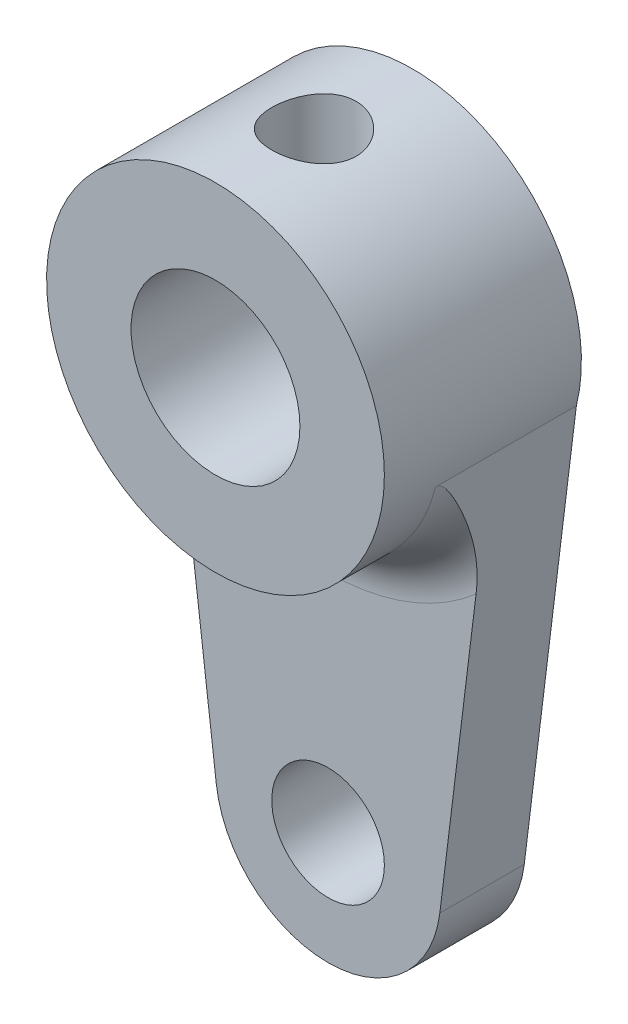
from build123d import *

# Parameters (mm, degrees)
SKETCH1_R             = 6
BOSS_EXTRUDE2_DEPTH   = 7
SKETCH1_4_R           = 2
BOSS_EXTRUDE3_DEPTH   = 3
SKETCH1_5_R           = 3
CUT_EXTRUDE1_DEPTH    = 8
FILLET5_R             = 2
M3_TAPPED_HOLE2_D     = 3
M3_TAPPED_HOLE2_DEPTH = 8.5
M3_TAPPED_HOLE2_TIP   = 0.901290929


with BuildPart() as part:
    # Sketch1 → Boss-Extrude2 (new body)
    with BuildSketch(Plane.XY):
        Circle(SKETCH1_R)
    extrude(amount=BOSS_EXTRUDE2_DEPTH)

    # Sketch1_4 → Boss-Extrude3 (add)
    with BuildSketch(Plane.XY):
        with BuildLine():
            Line((3.970026899, -16.488760087), (5.820835183, -1.45529302))
            ThreePointArc((5.820835183, -1.45529302), (0, -6), (-5.820835183, -1.45529302))
            Line((-5.820835183, -1.45529302), (-3.970026899, -16.488760087))
            ThreePointArc((-3.970026899, -16.488760087), (0, -20), (3.970026899, -16.488760087))
        make_face()
        with Locations((0, -16)):
            Circle(SKETCH1_4_R, mode=Mode.SUBTRACT)
    extrude(amount=BOSS_EXTRUDE3_DEPTH)

    # Sketch1_5 → Cut-Extrude1 (cut, through all)
    with BuildSketch(Plane.XY):
        Circle(SKETCH1_5_R)
    extrude(amount=CUT_EXTRUDE1_DEPTH, mode=Mode.SUBTRACT)

    # Fillet5
    fillet5_edges = [part.edges().sort_by_distance(p)[0] for p in [
        (0, -6, 3),
    ]]
    fillet(fillet5_edges, radius=FILLET5_R)

    # M3 Tapped Hole2
    with Locations(Plane(origin=(0, 7, 0), x_dir=(1, 0, 0), z_dir=(0, 1, 0))):
        with Locations((0, -3.5)):
            Hole(M3_TAPPED_HOLE2_D / 2, depth=M3_TAPPED_HOLE2_DEPTH)
            with Locations((0, 0, -(M3_TAPPED_HOLE2_DEPTH + M3_TAPPED_HOLE2_TIP / 2))):  # 118° drill point
                Cone(0, M3_TAPPED_HOLE2_D / 2, M3_TAPPED_HOLE2_TIP, mode=Mode.SUBTRACT)


solid = part.part
